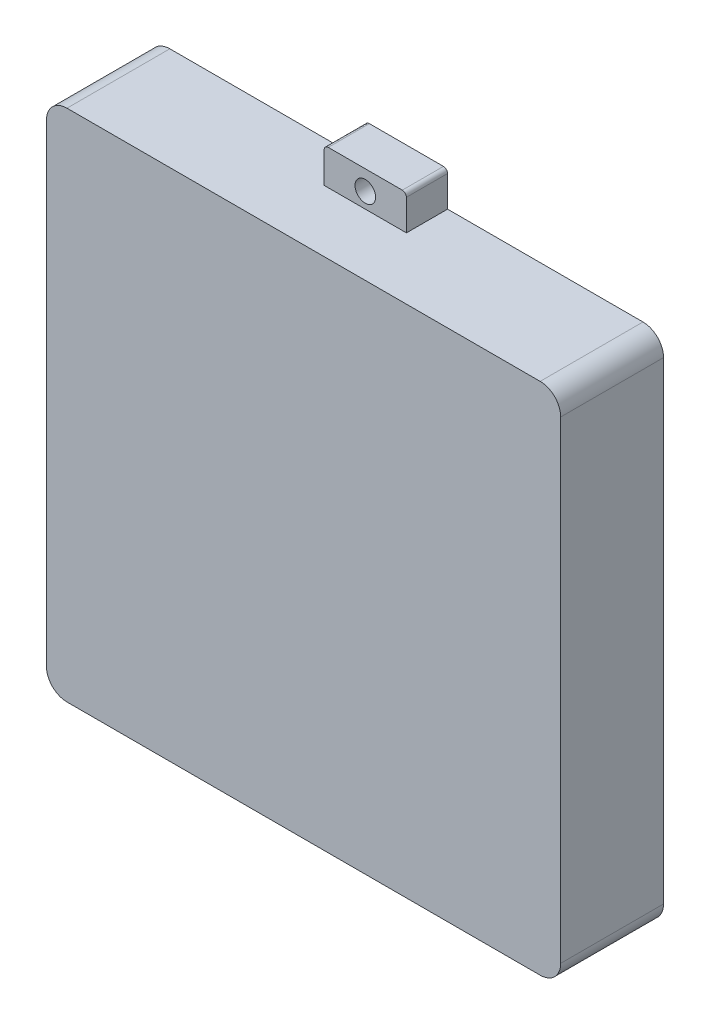
from build123d import *

# Parameters (mm, degrees)
SKETCH1_W           = 250
SKETCH1_H           = 250
BOSS_EXTRUDE1_DEPTH = 50
BOSS_EXTRUDE2_DEPTH = 20
SKETCH3_R           = 5
CUT_EXTRUDE1_DEPTH  = 25
SKETCH5_W           = 242
SKETCH5_H           = 242
CUT_EXTRUDE2_DEPTH  = 46
FILLET1_R           = 10
FILLET2_R           = 10


with BuildPart() as part:
    # Sketch1 → Boss-Extrude1 (new body)
    with BuildSketch(Plane.XY):
        with Locations((125, 125)):
            Rectangle(SKETCH1_W, SKETCH1_H)
    extrude(amount=BOSS_EXTRUDE1_DEPTH)

    # Sketch2 → Boss-Extrude2 (add)
    with BuildSketch(Plane.XY):
        with BuildLine():
            Line((105, 0), (105, -15))
            ThreePointArc((105, -15), (105.585786438, -16.414213562), (107, -17))
            Line((107, -17), (143, -17))
            ThreePointArc((143, -17), (144.414213562, -16.414213562), (145, -15))
            Line((145, -15), (145, 0))
            Line((145, 0), (105, 0))
        make_face()
    boss_extrude2 = extrude(amount=BOSS_EXTRUDE2_DEPTH)

    # Mirror1: Boss-Extrude2 across plane
    add(boss_extrude2.mirror(Plane.ZX.offset(125)))

    # Sketch3 → Cut-Extrude1 (cut)
    with BuildSketch(Plane(origin=(0, 0, 0), x_dir=(-1, 0, 0), z_dir=(0, 0, -1))):
        with Locations((-125, -7.5)):
            Circle(SKETCH3_R)
        with Locations((-125, 257.5)):
            Circle(SKETCH3_R)
    extrude(amount=-CUT_EXTRUDE1_DEPTH, mode=Mode.SUBTRACT)

    # Sketch5 → Cut-Extrude2 (cut)
    with BuildSketch(Plane(origin=(0, 0, 0), x_dir=(-1, 0, 0), z_dir=(0, 0, -1))):
        with Locations((-125, 125)):
            Rectangle(SKETCH5_W, SKETCH5_H)
    extrude(amount=-CUT_EXTRUDE2_DEPTH, mode=Mode.SUBTRACT)

    # Fillet1
    fillet1_edges = [part.edges().sort_by_distance(p)[0] for p in [
        (0, 250, 25),
        (250, 250, 25),
        (250, 0, 25),
        (0, 0, 25),
    ]]
    fillet(fillet1_edges, radius=FILLET1_R)

    # Fillet2
    fillet2_edges = [part.edges().sort_by_distance(p)[0] for p in [
        (246, 246, 23),
        (4, 246, 23),
        (4, 4, 23),
        (246, 4, 23),
    ]]
    fillet(fillet2_edges, radius=FILLET2_R)


solid = part.part
